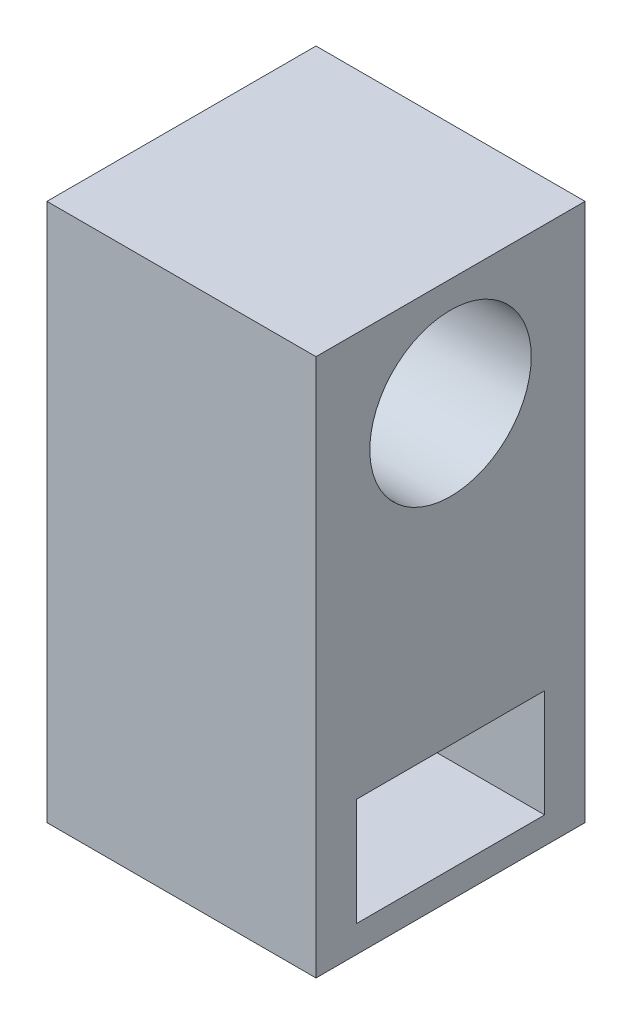
from build123d import *

# Parameters (mm, degrees)
SKETCH_1_W          = 100
SKETCH_1_H          = 200
EXTRUDE_1_DEPTH     = 100
SKETCH_2_R          = 30
SKETCH_2_W          = 70
SKETCH_2_H          = 40
CUT_EXTRUDE_1_DEPTH = 101


with BuildPart() as part:
    # 草图1 → 凸台-拉伸1 (new body)
    with BuildSketch(Plane.XY):
        with Locations((-8.762886598, -29.896907216)):
            Rectangle(SKETCH_1_W, SKETCH_1_H)
    extrude(amount=EXTRUDE_1_DEPTH)

    # 草图2 → 切除-拉伸1 (cut, through all)
    with BuildSketch(Plane(origin=(41.237113402, 0, 0), x_dir=(0, 0, -1), z_dir=(1, 0, 0))):
        with Locations((-50, 30.103092784)):
            Circle(SKETCH_2_R)
        with Locations((-50, -99.896907216)):
            Rectangle(SKETCH_2_W, SKETCH_2_H)
    extrude(amount=-CUT_EXTRUDE_1_DEPTH, mode=Mode.SUBTRACT)


solid = part.part
